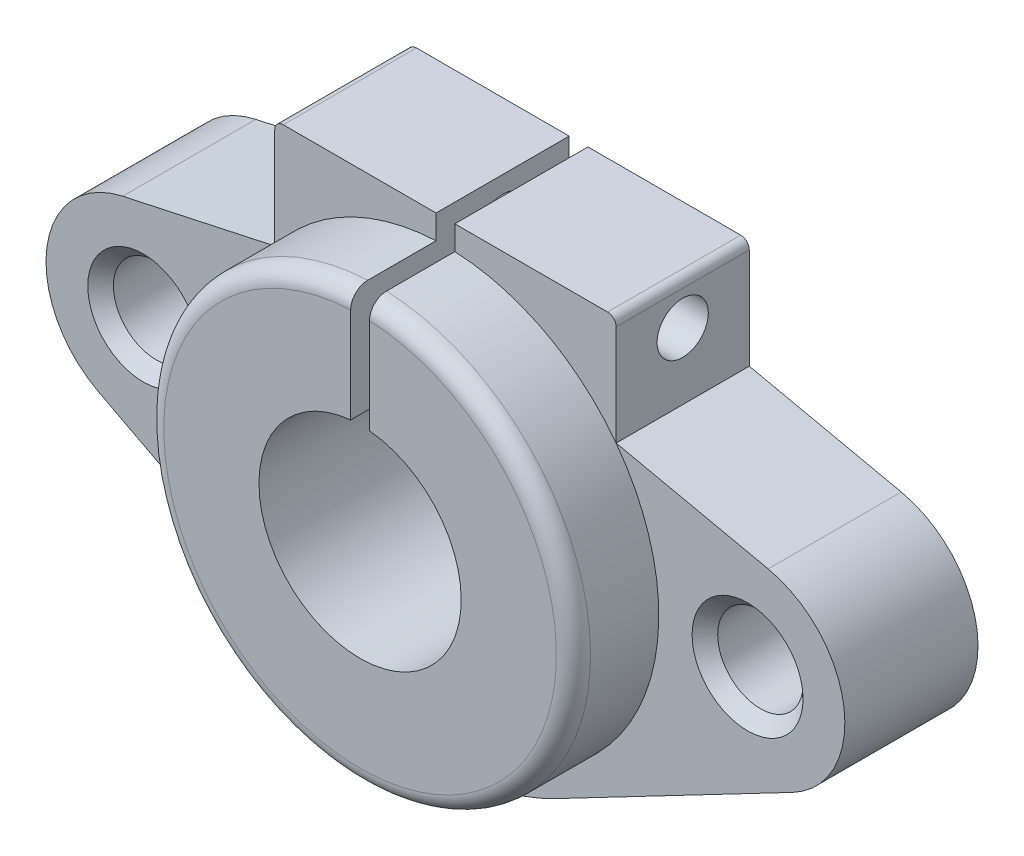
from build123d import *

# Parameters (mm, degrees)
CROQUIS1_R              = 12.5
CROQUIS1_R_2            = 5.925
SALIENTE_EXTRUIR1_DEPTH = 12.8
CROQUIS2_R              = 5.925
SALIENTE_EXTRUIR2_DEPTH = 7.8
CROQUIS3_R              = 2.5
CORTAR_EXTRUIR1_DEPTH   = 7.8
CORTAR_EXTRUIR2_DEPTH   = 13
REDONDEO1_R             = 1
CORTAR_EXTRUIR3_START   = -20
CROQUIS5_R              = 1.5
CORTAR_EXTRUIR3_DEPTH   = 20
REDONDEO2_R             = 0.5
CHAFL_N1_SIZE           = 0.75


with BuildPart() as part:
    # Croquis1 → Saliente-Extruir1 (new body)
    with BuildSketch(Plane.XY):
        Circle(CROQUIS1_R)
        Circle(CROQUIS1_R_2, mode=Mode.SUBTRACT)
    extrude(amount=SALIENTE_EXTRUIR1_DEPTH)

    # Croquis2 → Saliente-Extruir2 (add)
    with BuildSketch(Plane(origin=(0, 0, 0), x_dir=(-1, 0, 0), z_dir=(0, 0, -1))):
        with BuildLine():
            Line((-6.439548023, -12.318369262), (-20.340677966, -5.051417611))
            ThreePointArc((-20.340677966, -5.051417611), (-23.348755649, 0.76260056), (-18.906641236, 5.570818336))
            Line((-18.906641236, 5.570818336), (-10, 7.5))
            Line((-10, 7.5), (-10, 13.9))
            Line((-10, 13.9), (10, 13.9))
            Line((10, 13.9), (10, 7.5))
            Line((10, 7.5), (18.906641236, 5.570818336))
            ThreePointArc((18.906641236, 5.570818336), (23.348755649, 0.76260056), (20.340677966, -5.051417611))
            Line((20.340677966, -5.051417611), (6.439548023, -12.318369262))
            ThreePointArc((6.439548023, -12.318369262), (0, -13.9), (-6.439548023, -12.318369262))
        make_face()
        Circle(CROQUIS2_R, mode=Mode.SUBTRACT)
    extrude(amount=-SALIENTE_EXTRUIR2_DEPTH)

    # Croquis3 → Cortar-Extruir1 (cut)
    with BuildSketch(Plane(origin=(0, 0, 0), x_dir=(-1, 0, 0), z_dir=(0, 0, -1))):
        with Locations((-17.7, 0)):
            Circle(CROQUIS3_R)
        with Locations((17.7, 0)):
            Circle(CROQUIS3_R)
    extrude(amount=-CORTAR_EXTRUIR1_DEPTH, mode=Mode.SUBTRACT)

    # Croquis4 → Cortar-Extruir2 (cut)
    with BuildSketch(Plane(origin=(0, 0, 0), x_dir=(-1, 0, 0), z_dir=(0, 0, -1))):
        with BuildLine():
            Line((0.55, 13.9), (-0.55, 13.9))
            Line((-0.55, 13.9), (-0.55, 5.899417344))
            ThreePointArc((-0.55, 5.899417344), (0, 5.925), (0.55, 5.899417344))
            Line((0.55, 5.899417344), (0.55, 13.9))
        make_face()
    extrude(amount=-CORTAR_EXTRUIR2_DEPTH, mode=Mode.SUBTRACT)

    # Redondeo1
    redondeo1_edges = [part.edges().sort_by_distance(p)[0] for p in [
        (0, -12.5, 12.8),
    ]]
    fillet(redondeo1_edges, radius=REDONDEO1_R)

    # Croquis5 → Cortar-Extruir3 (cut)
    with BuildSketch(Plane(origin=(10, 0, 0), x_dir=(0, 0, -1), z_dir=(1, 0, 0)).offset(CORTAR_EXTRUIR3_START)):
        with Locations((-3.9, 11.4)):
            Circle(CROQUIS5_R)
    extrude(amount=CORTAR_EXTRUIR3_DEPTH, mode=Mode.SUBTRACT)

    # Redondeo2
    redondeo2_edges = [part.edges().sort_by_distance(p)[0] for p in [
        (10, 13.9, 3.9),
        (-10, 13.9, 3.9),
    ]]
    fillet(redondeo2_edges, radius=REDONDEO2_R)

    # Chaflán1
    chafl_n1_edges = [part.edges().sort_by_distance(p)[0] for p in [
        (20.2, 0, 7.8),
        (-15.2, 0, 7.8),
    ]]
    chamfer(chafl_n1_edges, length=CHAFL_N1_SIZE)


solid = part.part
